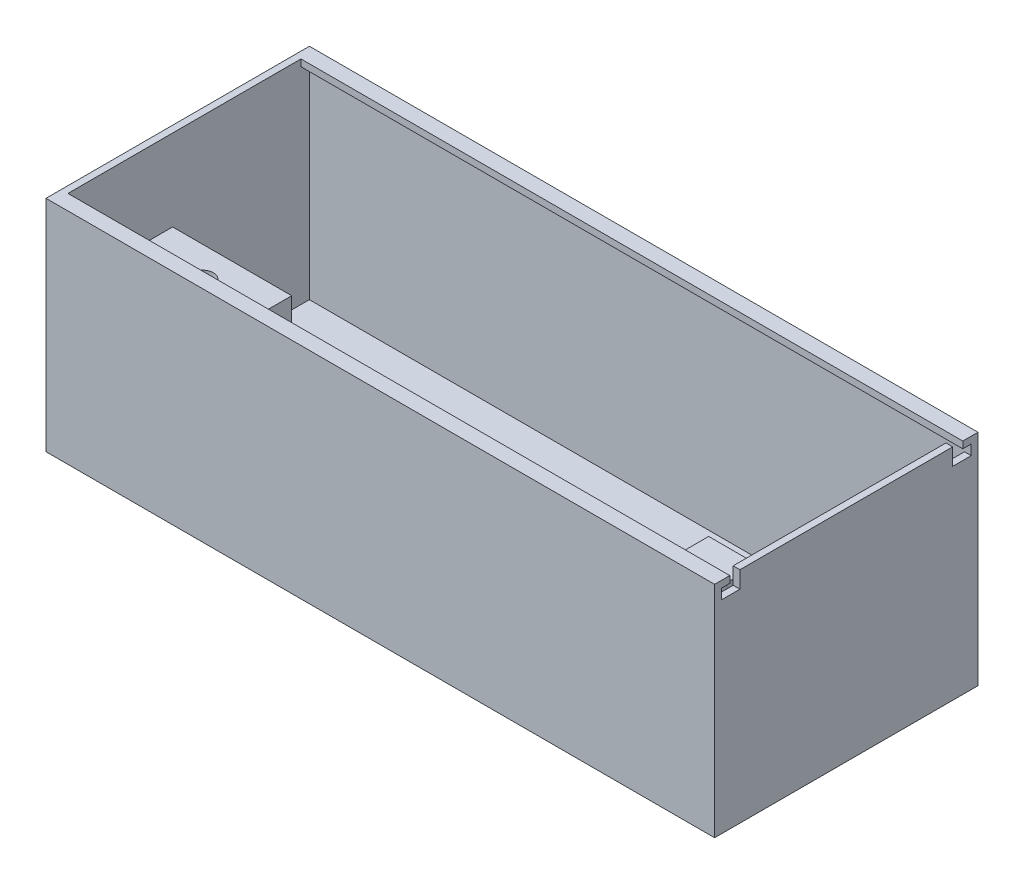
from build123d import *

# Parameters (mm, degrees)
SKETCH2_W                = 198
SKETCH2_H                = 78
BOSS_EXTRUDE1_DEPTH      = 50
BOSS_EXTRUDE1_DEPTH_BACK = 15
SHELL1_T                 = -2
BOSS_EXTRUDE2_REACH      = 198
SKETCH3_W                = 2.5
SKETCH3_H                = 2
CUT_EXTRUDE1_REACH       = 4
CROQUIS1_W               = 35.265
CROQUIS1_H               = 26
SALIENTE_EXTRUIR1_DEPTH  = 38.9
CORTAR_EXTRUIR1_DEPTH    = 2
CORTAR_EXTRUIR2_DEPTH    = 30
CROQUIS5_W               = 26
CROQUIS5_H               = 15
CORTAR_EXTRUIR3_DEPTH    = 35.265
CROQUIS6_W               = 12
CROQUIS6_H               = 3
SALIENTE_EXTRUIR2_DEPTH  = 3
CROQUIS7_W               = 26
CROQUIS7_H               = 15
CORTAR_EXTRUIR4_DEPTH    = 35.265


with BuildPart() as part:
    # Sketch2 → Boss-Extrude1 (new body, two sides)
    with BuildSketch(Plane(origin=(0, 0, 0), x_dir=(1, 0, 0), z_dir=(0, 1, 0))) as boss_extrude1_sk:
        Rectangle(SKETCH2_W, SKETCH2_H)
    extrude(amount=BOSS_EXTRUDE1_DEPTH)
    extrude(boss_extrude1_sk.sketch, amount=-BOSS_EXTRUDE1_DEPTH_BACK)

    # Shell1
    shell1_openings = [part.faces().sort_by_distance(p)[0] for p in [
        (0, 50, 0),
    ]]
    offset(amount=SHELL1_T, openings=shell1_openings, kind=Kind.INTERSECTION)

    # Sketch3 → Boss-Extrude2 (add, up to next)
    with BuildSketch(Plane(origin=(-97, 0, 0), x_dir=(0, 0, -1), z_dir=(1, 0, 0)), mode=Mode.PRIVATE) as boss_extrude2_sk1:
        with Locations((-35.75, 49)):
            Rectangle(SKETCH3_W, SKETCH3_H)
    boss_extrude2_tool1 = extrude(boss_extrude2_sk1.sketch, amount=BOSS_EXTRUDE2_REACH, mode=Mode.PRIVATE) - part.part
    add(boss_extrude2_tool1.solids().sort_by_distance((-97, 49, 35.75))[0])
    # Sketch3 → Boss-Extrude2 (add, up to next)
    with BuildSketch(Plane(origin=(-97, 0, 0), x_dir=(0, 0, -1), z_dir=(1, 0, 0)), mode=Mode.PRIVATE) as boss_extrude2_sk2:
        with Locations((35.75, 49)):
            Rectangle(SKETCH3_W, SKETCH3_H)
    boss_extrude2_tool2 = extrude(boss_extrude2_sk2.sketch, amount=BOSS_EXTRUDE2_REACH, mode=Mode.PRIVATE) - part.part
    add(boss_extrude2_tool2.solids().sort_by_distance((-97, 49, -35.75))[0])

    # Sketch4 → Cut-Extrude1 (cut, up to next)
    with BuildSketch(Plane.ZY.offset(-97), mode=Mode.PRIVATE) as cut_extrude1_sk1:
        Polygon((-37, 48), (-37, 45), (-31.5, 45), (-31.5, 50), (-34.5, 50), (-34.5, 48), align=None)
    cut_extrude1_tool1 = extrude(cut_extrude1_sk1.sketch, amount=-CUT_EXTRUDE1_REACH, mode=Mode.PRIVATE) & part.part
    add(cut_extrude1_tool1.solids().sort_by_distance((97, 47.166667, -33.916667))[0], mode=Mode.SUBTRACT)
    # Sketch4 → Cut-Extrude1 (cut, up to next)
    with BuildSketch(Plane.ZY.offset(-97), mode=Mode.PRIVATE) as cut_extrude1_sk2:
        Polygon((34.5, 48), (37, 48), (37, 45), (31.5, 45), (31.5, 50), (34.5, 50), align=None)
    cut_extrude1_tool2 = extrude(cut_extrude1_sk2.sketch, amount=-CUT_EXTRUDE1_REACH, mode=Mode.PRIVATE) & part.part
    add(cut_extrude1_tool2.solids().sort_by_distance((97, 47.166667, 33.916667))[0], mode=Mode.SUBTRACT)

    # Croquis1 → Saliente-Extruir1 (add)
    with BuildSketch(Plane(origin=(0, -13, 0), x_dir=(1, 0, 0), z_dir=(0, 1, 0))):
        with Locations((79.3675, -16.5)):
            Rectangle(CROQUIS1_W, CROQUIS1_H)
    saliente_extruir1 = extrude(amount=SALIENTE_EXTRUIR1_DEPTH)

    # Simetría1: Saliente-Extruir1 across plane
    add(saliente_extruir1.mirror(Plane(origin=(0, 0, 0), x_dir=(0, 0, 1), z_dir=(1, 0, 0))))

    # Croquis2 → Cortar-Extruir1 (cut)
    with BuildSketch(Plane(origin=(0, 25.9, 0), x_dir=(1, 0, 0), z_dir=(0, 1, 0))):
        with BuildLine():
            Line((82.41, -12.375), (82.41, -20.625))
            ThreePointArc((82.41, -20.625), (79.235, -23.8), (76.06, -20.625))
            Line((76.06, -20.625), (76.06, -12.375))
            ThreePointArc((76.06, -12.375), (79.235, -9.2), (82.41, -12.375))
        make_face()
    cortar_extruir1 = extrude(amount=-CORTAR_EXTRUIR1_DEPTH, mode=Mode.SUBTRACT)

    # Simetría2: Cortar-Extruir1 across plane
    add(cortar_extruir1.mirror(Plane(origin=(0, 0, 0), x_dir=(0, 0, 1), z_dir=(1, 0, 0))), mode=Mode.SUBTRACT)

    # Croquis3 → Cortar-Extruir2 (cut)
    with BuildSketch(Plane(origin=(0, 23.9, 0), x_dir=(1, 0, 0), z_dir=(0, 1, 0))):
        with BuildLine():
            Line((80.835, -13.2), (80.835, -19.8))
            ThreePointArc((80.835, -19.8), (79.235, -21.4), (77.635, -19.8))
            Line((77.635, -19.8), (77.635, -13.2))
            ThreePointArc((77.635, -13.2), (79.235, -11.6), (80.835, -13.2))
        make_face()
    cortar_extruir2 = extrude(amount=-CORTAR_EXTRUIR2_DEPTH, mode=Mode.SUBTRACT)

    # Simetría3: Cortar-Extruir2 across plane
    add(cortar_extruir2.mirror(Plane(origin=(0, 0, 0), x_dir=(0, 0, 1), z_dir=(1, 0, 0))), mode=Mode.SUBTRACT)

    # Croquis5 → Cortar-Extruir3 (cut)
    with BuildSketch(Plane.ZY.offset(-61.735)):
        with Locations((16.5, -5.5)):
            Rectangle(CROQUIS5_W, CROQUIS5_H)
    extrude(amount=-CORTAR_EXTRUIR3_DEPTH, mode=Mode.SUBTRACT)

    # Croquis6 → Saliente-Extruir2 (add)
    with BuildSketch(Plane.ZY.offset(-61.735)):
        with Locations((16.5, 3.5)):
            Rectangle(CROQUIS6_W, CROQUIS6_H)
    saliente_extruir2 = extrude(amount=SALIENTE_EXTRUIR2_DEPTH)

    # Croquis7 → Cortar-Extruir4 (cut)
    with BuildSketch(Plane(origin=(-61.735, 0, 0), x_dir=(0, 0, -1), z_dir=(1, 0, 0))):
        with Locations((-16.5, -5.5)):
            Rectangle(CROQUIS7_W, CROQUIS7_H)
    extrude(amount=-CORTAR_EXTRUIR4_DEPTH, mode=Mode.SUBTRACT)

    # Simetría7: Saliente-Extruir2 across plane
    add(saliente_extruir2.mirror(Plane(origin=(0, 0, 0), x_dir=(0, 0, 1), z_dir=(1, 0, 0))))


solid = part.part
